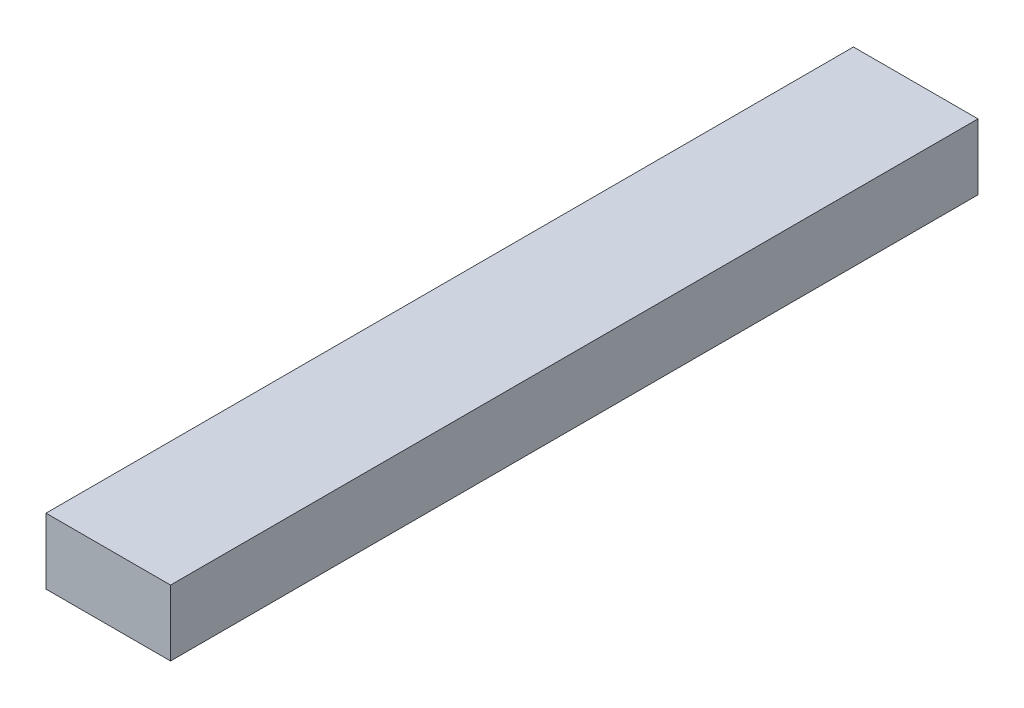
from build123d import *

# Parameters (mm, degrees)
SKETCH1_W           = 19.7104
SKETCH1_H           = 127.79375
BOSS_EXTRUDE1_DEPTH = 10.414


with BuildPart() as part:
    # Sketch1 → Boss-Extrude1 (new body)
    with BuildSketch(Plane(origin=(0, 0, 0), x_dir=(1, 0, 0), z_dir=(0, 1, 0))):
        with Locations((9.8552, 63.896875)):
            Rectangle(SKETCH1_W, SKETCH1_H)
    extrude(amount=BOSS_EXTRUDE1_DEPTH)


solid = part.part
